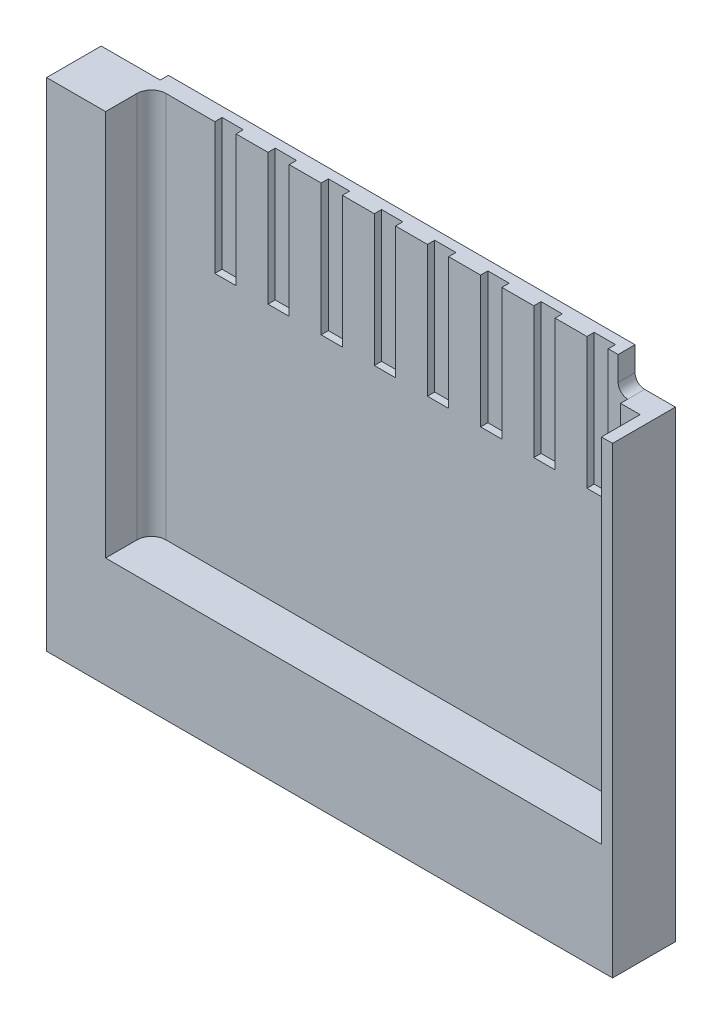
from build123d import *

# Parameters (mm, degrees)
BOSS_EXTRUDE1_DEPTH = 1.3
SKETCH3_W           = 1.22
SKETCH3_H           = 0.25
CUT_EXTRUDE1_DEPTH  = 0.17
CUT_EXTRUDE2_DEPTH  = 0.17
CUT_EXTRUDE3_DEPTH  = 0.1
SKETCH6_W           = 2.565
SKETCH6_H           = 1.079999998
SKETCH6_W_2         = 2.605000011
SKETCH6_H_2         = 1.079999997
CUT_EXTRUDE4_DEPTH  = 0.15
CUT_EXTRUDE5_DEPTH  = 0.95
SKETCH8_W           = 0.405
SKETCH8_H           = 7.3
BOSS_EXTRUDE2_DEPTH = 0.15
FILLET1_R           = 0.3
SKETCH9_W           = 0.44
SKETCH9_H           = 2.72
CUT_EXTRUDE6_DEPTH  = 0.15
LPATTERN1_COUNT     = 8
LPATTERN1_PITCH     = 1.1


with BuildPart() as part:
    # Sketch2 → Boss-Extrude1 (new body)
    with BuildSketch(Plane.XY):
        with BuildLine():
            Line((5.855, 5.140000001), (4.635, 5.140000001))
            Line((4.635, 5.140000001), (-5.02, 5.140000001))
            Line((-5.02, 5.140000001), (-5.02, 4.640000001))
            ThreePointArc((-5.02, 4.640000001), (-5.078578644, 4.498578644), (-5.22, 4.440000001))
            Line((-5.22, 4.440000001), (-5.855, 4.440000001))
            Line((-5.855, 4.440000001), (-5.855, -5.139999999))
            Line((-5.855, -5.139999999), (-5.205000011, -5.139999999))
            Line((-5.205000011, -5.139999999), (-2.6, -5.139999999))
            Line((-2.6, -5.139999999), (1.17, -5.139999999))
            Line((1.17, -5.139999999), (3.735, -5.139999999))
            Line((3.735, -5.139999999), (5.855, -5.139999999))
            Line((5.855, -5.139999999), (5.855, -4.659999975))
            Line((5.855, -4.659999975), (5.855, -3.259999975))
            Line((5.855, -3.259999975), (5.855, -1.150000033))
            Line((5.855, -1.150000033), (5.855, 0.439999967))
            Line((5.855, 0.439999967), (5.855, 4.890000001))
            Line((5.855, 4.890000001), (5.855, 5.140000001))
        make_face()
    extrude(amount=BOSS_EXTRUDE1_DEPTH)

    # Sketch3 → Cut-Extrude1 (cut)
    with BuildSketch(Plane(origin=(0, 0, 0), x_dir=(-1, 0, 0), z_dir=(0, 0, -1))):
        with Locations((-5.245, 5.015000001)):
            Rectangle(SKETCH3_W, SKETCH3_H)
    extrude(amount=-CUT_EXTRUDE1_DEPTH, mode=Mode.SUBTRACT)

    # Sketch4 → Cut-Extrude2 (cut)
    with BuildSketch(Plane(origin=(0, 0, 0), x_dir=(-1, 0, 0), z_dir=(0, 0, -1))):
        with BuildLine():
            Line((-5.855, -3.259999975), (-5.190000002, -3.259999975))
            ThreePointArc((-5.190000002, -3.259999975), (-5.013223307, -3.333223279), (-4.940000002, -3.509999975))
            Line((-4.940000002, -3.509999975), (-4.940000002, -4.409999975))
            ThreePointArc((-4.940000002, -4.409999975), (-5.013223307, -4.58677667), (-5.190000002, -4.659999975))
            Line((-5.190000002, -4.659999975), (-5.855, -4.659999975))
            Line((-5.855, -4.659999975), (-5.855, -3.259999975))
        make_face()
        Polygon((-4.455, -4.649999999), (-4.685, -4.649999999), (-4.845000002, -1.660000037), (-4.845000002, -1.150000033), (-5.855, -1.150000033), (-5.855, 0.439999967), (-4.865000002, 0.439999967), (-4.865000002, -0.110000037), (-4.455, -0.110000037), align=None)
    extrude(amount=-CUT_EXTRUDE2_DEPTH, mode=Mode.SUBTRACT)

    # Sketch5 → Cut-Extrude3 (cut)
    with BuildSketch(Plane(origin=(0, 0, 0), x_dir=(-1, 0, 0), z_dir=(0, 0, -1))):
        Polygon((5.205000011, -5.139999999), (2.6, -5.139999999), (-1.17, -5.139999999), (-3.735, -5.139999999), (-3.735, -4.060000001), (-3.735, -2.254355959), (-3.735, 1.690000007), (5.205000011, 1.690000007), (5.205000011, -2.080000002), (5.205000011, -4.060000002), align=None)
    extrude(amount=-CUT_EXTRUDE3_DEPTH, mode=Mode.SUBTRACT)

    # Sketch6 → Cut-Extrude4 (cut)
    with BuildSketch(Plane(origin=(0, 0, 0.1), x_dir=(-1, 0, 0), z_dir=(0, 0, -1))):
        with Locations((-2.4525, -4.6)):
            Rectangle(SKETCH6_W, SKETCH6_H)
        with Locations((3.902500006, -4.600000001)):
            Rectangle(SKETCH6_W_2, SKETCH6_H_2)
        with BuildLine():
            Line((5.205000011, 1.690000007), (5.205000011, -2.080000002))
            ThreePointArc((5.205000011, -2.080000002), (5.087842724, -2.362842714), (4.805000011, -2.480000002))
            Line((4.805000011, -2.480000002), (-3.375, -2.480000002))
            ThreePointArc((-3.375, -2.480000002), (-3.587435422, -2.41892653), (-3.735, -2.254355959))
            Line((-3.735, -2.254355959), (-3.735, 1.690000007))
            Line((-3.735, 1.690000007), (5.205000011, 1.690000007))
        make_face()
    extrude(amount=-CUT_EXTRUDE4_DEPTH, mode=Mode.SUBTRACT)


with BuildPart() as body_2:
    # Mirror1: mirrored copy
    add(part.part.mirror(Plane(origin=(-5.855, 4.440000001, 1.3), x_dir=(0, 0, 1), z_dir=(1, 0, 0))))

    # Sketch7 → Cut-Extrude5 (cut)
    with BuildSketch(Plane.XY.offset(1.3)):
        Polygon((-6.085, -2.859999999), (-16.345, -2.859999999), (-16.345, 5.140000001), (-16.345, 5.61631281), (-6.085, 5.61631281), align=None)
    extrude(amount=-CUT_EXTRUDE5_DEPTH, mode=Mode.SUBTRACT)

    # Sketch8 → Boss-Extrude2 (add)
    with BuildSketch(Plane.XY.offset(0.35)):
        with Locations((-6.2875, 0.790000001)):
            Rectangle(SKETCH8_W, SKETCH8_H)
    extrude(amount=BOSS_EXTRUDE2_DEPTH)

    # Fillet1
    fillet1_edges = [body_2.edges().sort_by_distance(p)[0] for p in [
        (-16.345, 1.140000001, 0.35),
    ]]
    fillet(fillet1_edges, radius=FILLET1_R)

    # Sketch9 → Cut-Extrude6 (cut)
    with BuildSketch(Plane.XY.offset(0.35)):
        with Locations((-7.115, 3.780000001)):
            Rectangle(SKETCH9_W, SKETCH9_H)
    cut_extrude6 = extrude(amount=-CUT_EXTRUDE6_DEPTH, mode=Mode.SUBTRACT)

    # LPattern1: Cut-Extrude6 ×8
    with Locations(*[(-i * LPATTERN1_PITCH, 0, 0) for i in range(1, LPATTERN1_COUNT)]):
        add(cut_extrude6, mode=Mode.SUBTRACT)


solid = body_2.part
